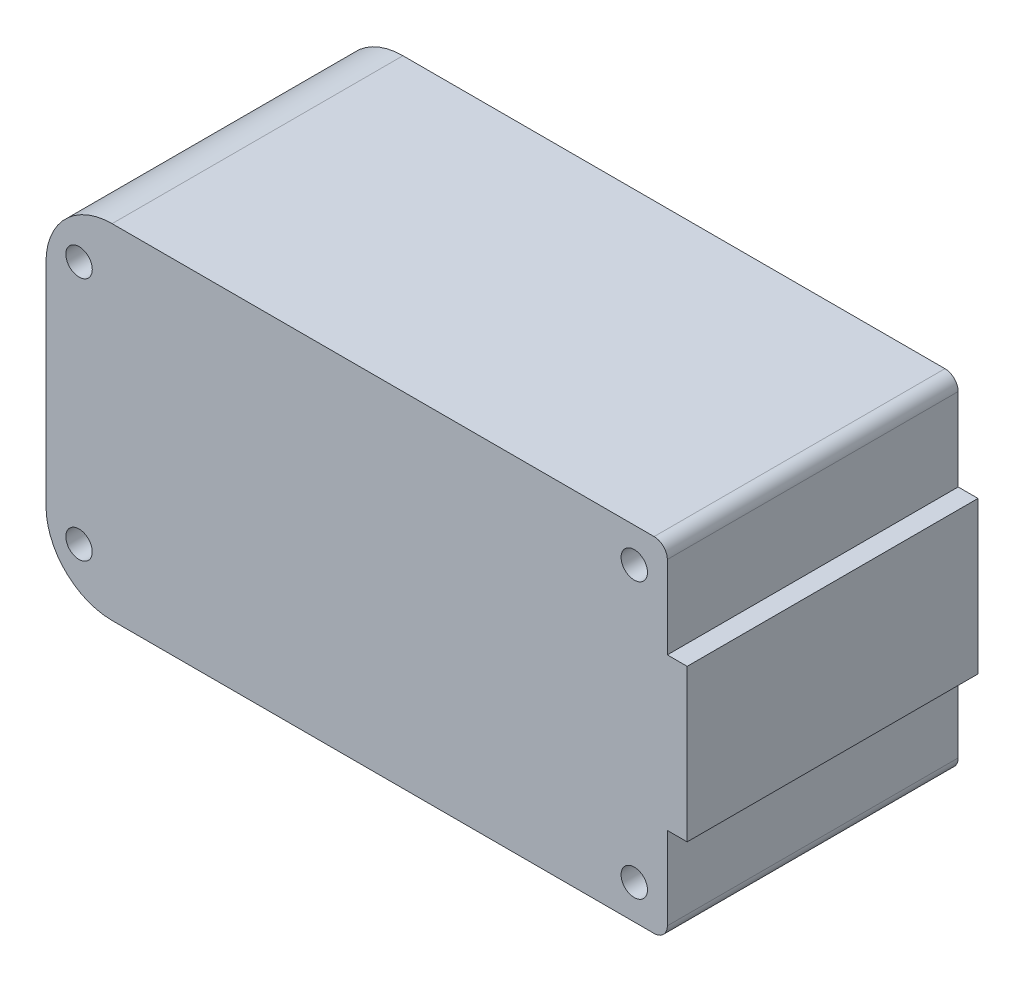
from build123d import *

# Parameters (mm, degrees)
SKETCH1_R           = 1
BOSS_EXTRUDE1_DEPTH = 11
FILLET1_R           = 5
FILLET2_R           = 1


with BuildPart() as part:
    # Sketch1 → Boss-Extrude1 (new body, symmetric)
    with BuildSketch(Plane.XY):
        Polygon((35.5, -13), (-11.5, -13), (-11.5, 13), (35.5, 13), (35.5, 5.75), (37, 5.75), (37, -5.75), (35.5, -5.75), align=None)
        with Locations((-9, 9.25)):
            Circle(SKETCH1_R, mode=Mode.SUBTRACT)
        with Locations((33, 10.4)):
            Circle(SKETCH1_R, mode=Mode.SUBTRACT)
        with Locations((33, -10.4)):
            Circle(SKETCH1_R, mode=Mode.SUBTRACT)
        with Locations((-9, -9.25)):
            Circle(SKETCH1_R, mode=Mode.SUBTRACT)
    extrude(amount=BOSS_EXTRUDE1_DEPTH, both=True)

    # Fillet1
    fillet1_edges = [part.edges().sort_by_distance(p)[0] for p in [
        (-11.5, 13, 0),
        (-11.5, -13, 0),
    ]]
    fillet(fillet1_edges, radius=FILLET1_R)

    # Fillet2
    fillet2_edges = [part.edges().sort_by_distance(p)[0] for p in [
        (35.5, 13, 0),
        (35.5, -13, 0),
    ]]
    fillet(fillet2_edges, radius=FILLET2_R)


solid = part.part
